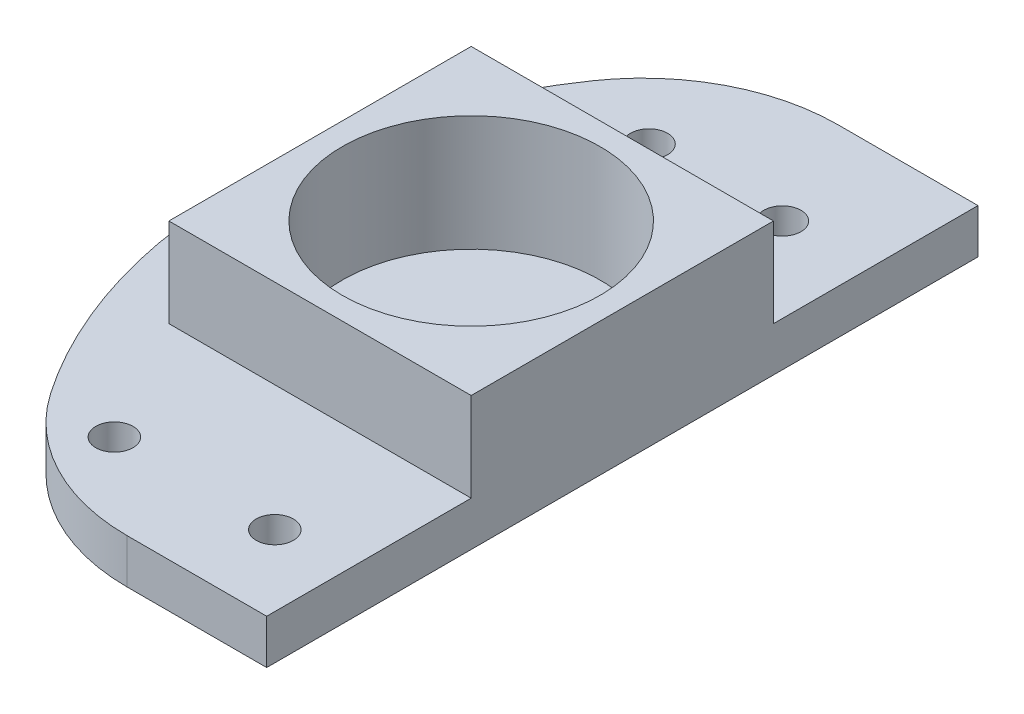
from build123d import *

# Parameters (mm, degrees)
SKETCH2_R                  = 57.15
BOSS_EXTRUDE1_DEPTH        = 19.05
SKETCH3_R                  = 18.415
CUT_EXTRUDE1_DEPTH         = 16.51
SKETCH3_4_R                = 57.15
SKETCH3_4_W                = 43.18
SKETCH3_4_H                = 43.18
CUT_EXTRUDE2_DEPTH         = 12.7
SKETCH5_W                  = 114.3
SKETCH5_H                  = 114.3
CUT_EXTRUDE3_DEPTH         = 12.7
FILLET1_R                  = 27.94
F_4_0_209_DIAMETER_HOLE1_D = 5.3086


with BuildPart() as part:
    # Sketch2 → Boss-Extrude1 (new body)
    with BuildSketch(Plane(origin=(0, 0, 0), x_dir=(1, 0, 0), z_dir=(0, 1, 0))):
        with BuildLine():
            Line((-57.15, 57.15), (-57.15, -6.4e-08))
            ThreePointArc((-57.15, -6.4e-08), (-40.411152555, 40.411152534), (3.4e-08, 57.15))
            Line((3.4e-08, 57.15), (-57.15, 57.15))
        make_face()
        Circle(SKETCH2_R)
        with BuildLine():
            ThreePointArc((3.4e-08, 57.15), (40.411152557, 40.411152533), (57.15, 0))
            Line((57.15, 0), (57.15, 57.15))
            Line((57.15, 57.15), (3.4e-08, 57.15))
        make_face()
        with BuildLine():
            ThreePointArc((57.15, 0), (40.411152582, -40.411152508), (1.05e-07, -57.15))
            Line((1.05e-07, -57.15), (57.15, -57.15))
            Line((57.15, -57.15), (57.15, 0))
        make_face()
        with BuildLine():
            Line((-57.15, -6.4e-08), (-57.15, -57.15))
            Line((-57.15, -57.15), (1.05e-07, -57.15))
            ThreePointArc((1.05e-07, -57.15), (-40.411152485, -40.411152604), (-57.15, -6.4e-08))
        make_face()
    extrude(amount=BOSS_EXTRUDE1_DEPTH)

    # Sketch3 → Cut-Extrude1 (cut)
    with BuildSketch(Plane(origin=(0, 19.05, 0), x_dir=(1, 0, 0), z_dir=(0, 1, 0))):
        with Locations(Location((0, 0, 0), (0, 0, 270))):
            Circle(SKETCH3_R)
    extrude(amount=-CUT_EXTRUDE1_DEPTH, mode=Mode.SUBTRACT)

    # Sketch3_4 → Cut-Extrude2 (cut)
    with BuildSketch(Plane(origin=(0, 19.05, 0), x_dir=(1, 0, 0), z_dir=(0, 1, 0))):
        Circle(SKETCH3_4_R)
        Rectangle(SKETCH3_4_W, SKETCH3_4_H, mode=Mode.SUBTRACT)
        with BuildLine():
            Line((-57.15, -57.15), (9.5e-08, -57.15))
            ThreePointArc((9.5e-08, -57.15), (-40.411152547, -40.411152543), (-57.15, 1.01e-07))
            Line((-57.15, 1.01e-07), (-57.15, -57.15))
        make_face()
        with BuildLine():
            ThreePointArc((-57.15, 1.01e-07), (-40.411152509, 40.411152581), (0, 57.15))
            Line((0, 57.15), (-57.15, 57.15))
            Line((-57.15, 57.15), (-57.15, 1.01e-07))
        make_face()
        with BuildLine():
            ThreePointArc((0, 57.15), (40.411152545, 40.411152545), (57.15, 0))
            Line((57.15, 0), (57.15, 57.15))
            Line((57.15, 57.15), (0, 57.15))
        make_face()
        with BuildLine():
            Line((57.15, -57.15), (57.15, 0))
            ThreePointArc((57.15, 0), (40.411152578, -40.411152511), (9.5e-08, -57.15))
            Line((9.5e-08, -57.15), (57.15, -57.15))
        make_face()
    extrude(amount=-CUT_EXTRUDE2_DEPTH, mode=Mode.SUBTRACT)

    # Sketch5 → Cut-Extrude3 (cut)
    with BuildSketch(Plane(origin=(0, 6.35, 0), x_dir=(1, 0, 0), z_dir=(0, 1, 0))):
        Rectangle(SKETCH5_W, SKETCH5_H)
        with BuildLine():
            Line((21.59, 50.8), (21.59, -50.8))
            Line((21.59, -50.8), (-10.767475048, -50.8))
            ThreePointArc((-10.767475048, -50.8), (-33.401, 0), (-10.767475048, 50.8))
            Line((-10.767475048, 50.8), (21.59, 50.8))
        make_face(mode=Mode.SUBTRACT)
    extrude(amount=-CUT_EXTRUDE3_DEPTH, mode=Mode.SUBTRACT)

    # Fillet1
    fillet1_edges = [part.edges().sort_by_distance(p)[0] for p in [
        (-10.767475048, 3.175, -50.8),
        (-10.767475048, 3.175, 50.8),
    ]]
    fillet(fillet1_edges, radius=FILLET1_R)

    # 4 _0.209_ Diameter Hole1 (through all)
    with Locations(Plane(origin=(0, 6.35, 0), x_dir=(1, 0, 0), z_dir=(0, 1, 0))):
        with Locations((-9.525, 34.925), (9.525, 34.925), (11.456890961, -39.511615824), (-11.456890961, -39.511615824)):
            Hole(F_4_0_209_DIAMETER_HOLE1_D / 2)


solid = part.part
